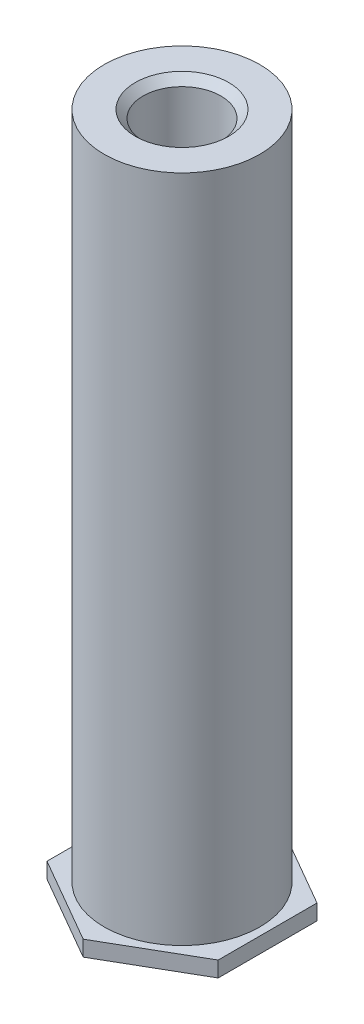
from build123d import *

# Parameters (mm, degrees)
EXTRUDE_1_DEPTH              = 0.5
SKETCH_2_R                   = 2.5
EXTRUDE_2_DEPTH              = 21.5
HOLE_WIZARD_M3_1_D           = 2.5
HOLE_WIZARD_M3_1_DEPTH       = 7.5
HOLE_WIZARD_M3_1_CSINK_D     = 3
HOLE_WIZARD_M3_1_CSINK_ANGLE = 90
HOLE_WIZARD_M3_1_TIP         = 0.751075774


with BuildPart() as part:
    # 草图1 → 凸台-拉伸1 (new body)
    with BuildSketch(Plane(origin=(0, 0, 0), x_dir=(1, 0, 0), z_dir=(0, 1, 0))):
        Polygon((0, -3.175426481), (2.75, -1.58771324), (2.75, 1.58771324), (0, 3.175426481), (-2.75, 1.58771324), (-2.75, -1.58771324), align=None)
    extrude(amount=EXTRUDE_1_DEPTH)

    # 草图2 → 凸台-拉伸2 (add)
    with BuildSketch(Plane(origin=(0, 0.5, 0), x_dir=(1, 0, 0), z_dir=(0, 1, 0))):
        Circle(SKETCH_2_R)
    extrude(amount=EXTRUDE_2_DEPTH)

    # M3 螺纹孔1
    with Locations(Plane(origin=(0, 22, 0), x_dir=(1, 0, 0), z_dir=(0, 1, 0))):
        with Locations((0, 0)):
            CounterSinkHole(HOLE_WIZARD_M3_1_D / 2, HOLE_WIZARD_M3_1_CSINK_D / 2, depth=HOLE_WIZARD_M3_1_DEPTH, counter_sink_angle=HOLE_WIZARD_M3_1_CSINK_ANGLE)
            with Locations((0, 0, -(HOLE_WIZARD_M3_1_DEPTH + HOLE_WIZARD_M3_1_TIP / 2))):  # 118° drill point
                Cone(0, HOLE_WIZARD_M3_1_D / 2, HOLE_WIZARD_M3_1_TIP, mode=Mode.SUBTRACT)


solid = part.part
